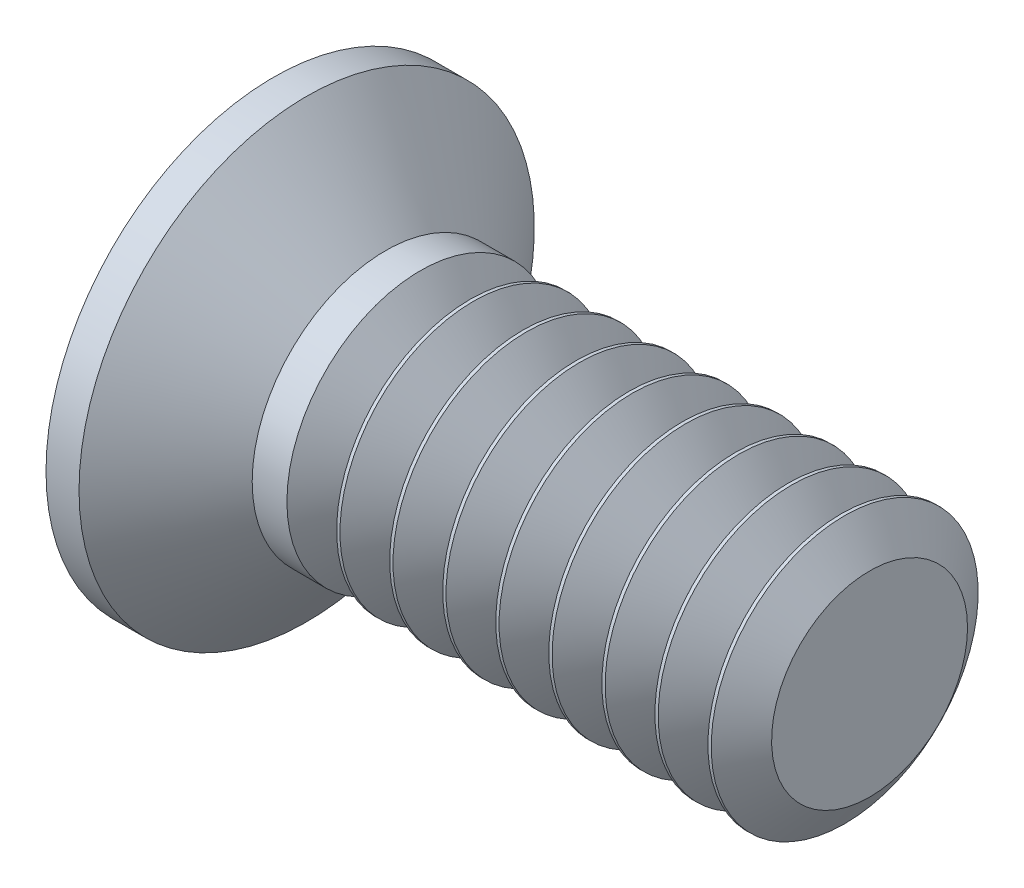
from build123d import *

# Parameters (mm, degrees)
SKETCH3_W         = 0.7366
SKETCH3_H         = 3.4544
SKETCH4_W         = 0.3683
SKETCH4_H         = 0.3683
CIRPATTERN1_COUNT = 2
CIRPATTERN1_ANGLE = 90
THDSCHPAT_COUNT   = 9
THDSCHPAT_PITCH   = 0.56515


with BuildPart() as part:
    # BodySke → Base-Revolve (revolve)
    with BuildSketch(Plane.XY):
        Polygon((0, 0), (0, 2.4257), (0.35193134, 2.4257), (1.1938, 1.4224), (6.35, 1.4224), (6.35, 0), align=None)
    revolve(axis=Axis((-6.35, 0, 0), (1, 0, 0)))

    # Sketch3 → Cross section 0
    with BuildSketch(Plane.ZY):
        Rectangle(SKETCH3_W, SKETCH3_H)
    # Sketch4 → Cross section 1
    with BuildSketch(Plane.ZY.offset(-2.2606)):
        Rectangle(SKETCH4_W, SKETCH4_H)
    cross = loft(mode=Mode.SUBTRACT)

    # CirPattern1: Cross ×2 about axis
    cirpattern1_axis = Axis((0, 0, 0), (1, 0, 0))
    for i in range(1, CIRPATTERN1_COUNT):
        add(cross.rotate(cirpattern1_axis, i * CIRPATTERN1_ANGLE / (CIRPATTERN1_COUNT - 1)), mode=Mode.SUBTRACT)

    # ThdSchSke → ThreadSchematic (revolve, cut)
    with BuildSketch(Plane.XY):
        Polygon((1.8288254, -1.04394), (1.563824855, -1.4224), (1.563824855, -1.778), (2.093825945, -1.778), (2.093825945, -1.4224), align=None)
    threadschematic = revolve(axis=Axis((-3.175, 0, 0), (1, 0, 0)), mode=Mode.SUBTRACT)

    # ThdSchPat: ThreadSchematic ×9
    with Locations(*[(i * THDSCHPAT_PITCH, 0, 0) for i in range(1, THDSCHPAT_COUNT)]):
        add(threadschematic, mode=Mode.SUBTRACT)


solid = part.part
